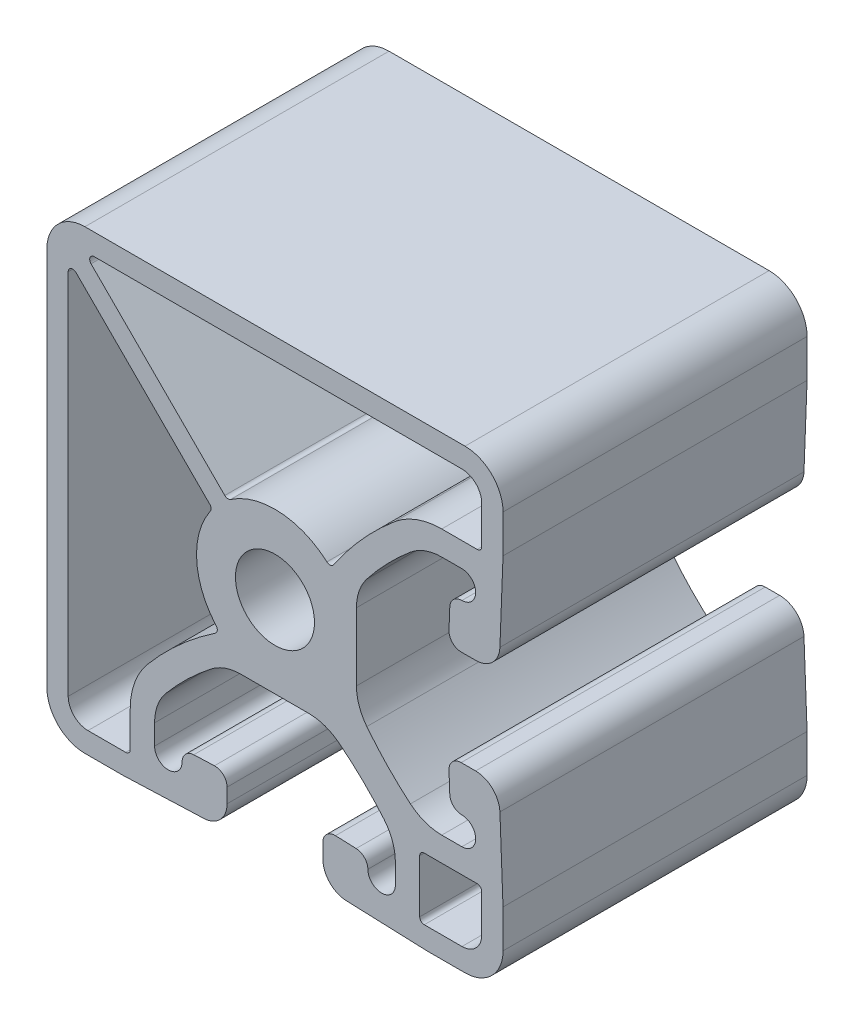
from build123d import *

# Parameters (mm, degrees)
SKETCH1_R      = 3.302
EXTRUDE1_DEPTH = 25.4


with BuildPart() as part:
    # Sketch1 → Extrude1 (new body)
    with BuildSketch(Plane.XY):
        with BuildLine():
            Line((15.875, 19.05), (-15.875, 19.05))
            ThreePointArc((-15.875, 19.05), (-18.12006403, 18.12006403), (-19.05, 15.875))
            Line((-19.05, 15.875), (-19.05, -15.875))
            ThreePointArc((-19.05, -15.875), (-18.12006403, -18.12006403), (-15.875, -19.05))
            Line((-15.875, -19.05), (-12.7, -19.05))
            Line((-12.7, -19.05), (-5.954495972, -18.790863874))
            ThreePointArc((-5.954495972, -18.790863874), (-4.568340141, -18.169354143), (-4.0005, -16.760361628))
            Line((-4.0005, -16.760361628), (-4.0005, -15.552069001))
            ThreePointArc((-4.0005, -15.552069001), (-4.312003742, -14.819989072), (-5.055502014, -14.536817878))
            Line((-5.055502014, -14.536817878), (-6.782702014, -14.603170209))
            ThreePointArc((-6.782702014, -14.603170209), (-7.475165883, -14.913287543), (-7.759698458, -15.616651022))
            ThreePointArc((-7.759698458, -15.616651022), (-8.91004969, -16.763999564), (-10.0584, -15.614648356))
            Line((-10.0584, -15.614648356), (-10.0584, -13.931647412))
            ThreePointArc((-10.0584, -13.931647412), (-9.812696364, -12.53999053), (-9.105295238, -11.316608824))
            ThreePointArc((-9.105295238, -11.316608824), (-7.314841404, -9.397406099), (-5.335891418, -7.673219048))
            ThreePointArc((-5.335891418, -7.673219048), (-4.154656747, -7.029801128), (-2.828100791, -6.8072))
            Line((-2.828100791, -6.8072), (0, -6.8072))
            Line((0, -6.8072), (2.828100791, -6.8072))
            ThreePointArc((2.828100791, -6.8072), (4.154656747, -7.029801128), (5.335891418, -7.673219048))
            ThreePointArc((5.335891418, -7.673219048), (7.314841404, -9.397406099), (9.105295238, -11.316608824))
            ThreePointArc((9.105295238, -11.316608824), (9.812696364, -12.53999053), (10.0584, -13.931647412))
            Line((10.0584, -13.931647412), (10.0584, -15.614648356))
            ThreePointArc((10.0584, -15.614648356), (8.91004969, -16.763999564), (7.759698458, -15.616651022))
            ThreePointArc((7.759698458, -15.616651022), (7.475165883, -14.913287543), (6.782702014, -14.603170209))
            Line((6.782702014, -14.603170209), (5.055502014, -14.536817878))
            ThreePointArc((5.055502014, -14.536817878), (4.312003742, -14.819989072), (4.0005, -15.552069001))
            Line((4.0005, -15.552069001), (4.0005, -16.760361628))
            ThreePointArc((4.0005, -16.760361628), (4.568340141, -18.169354143), (5.954495972, -18.790863874))
            Line((5.954495972, -18.790863874), (12.7, -19.05))
            Line((12.7, -19.05), (15.875, -19.05))
            ThreePointArc((15.875, -19.05), (18.12006403, -18.12006403), (19.05, -15.875))
            Line((19.05, -15.875), (19.05, -12.7))
            Line((19.05, -12.7), (18.790863874, -5.954495972))
            ThreePointArc((18.790863874, -5.954495972), (18.169354143, -4.568340141), (16.760361628, -4.0005))
            Line((16.760361628, -4.0005), (15.552069001, -4.0005))
            ThreePointArc((15.552069001, -4.0005), (14.819989072, -4.312003742), (14.536817878, -5.055502014))
            Line((14.536817878, -5.055502014), (14.603170209, -6.782702014))
            ThreePointArc((14.603170209, -6.782702014), (14.913287543, -7.475165883), (15.616651022, -7.759698458))
            ThreePointArc((15.616651022, -7.759698458), (16.763999564, -8.91004969), (15.614648356, -10.0584))
            Line((15.614648356, -10.0584), (13.931647412, -10.0584))
            ThreePointArc((13.931647412, -10.0584), (12.53999053, -9.812696364), (11.316608824, -9.105295238))
            ThreePointArc((11.316608824, -9.105295238), (9.397406099, -7.314841404), (7.673219048, -5.335891418))
            ThreePointArc((7.673219048, -5.335891418), (7.029801128, -4.154656747), (6.8072, -2.828100791))
            Line((6.8072, -2.828100791), (6.8072, 0))
            Line((6.8072, 0), (6.8072, 2.828100791))
            ThreePointArc((6.8072, 2.828100791), (7.029801128, 4.154656747), (7.673219048, 5.335891418))
            ThreePointArc((7.673219048, 5.335891418), (9.397406099, 7.314841404), (11.316608824, 9.105295238))
            ThreePointArc((11.316608824, 9.105295238), (12.53999053, 9.812696364), (13.931647412, 10.0584))
            Line((13.931647412, 10.0584), (15.614648356, 10.0584))
            ThreePointArc((15.614648356, 10.0584), (16.763999564, 8.91004969), (15.616651022, 7.759698458))
            ThreePointArc((15.616651022, 7.759698458), (14.913287543, 7.475165883), (14.603170209, 6.782702014))
            Line((14.603170209, 6.782702014), (14.536817878, 5.055502014))
            ThreePointArc((14.536817878, 5.055502014), (14.819989072, 4.312003742), (15.552069001, 4.0005))
            Line((15.552069001, 4.0005), (16.760361628, 4.0005))
            ThreePointArc((16.760361628, 4.0005), (18.169354143, 4.568340141), (18.790863874, 5.954495972))
            Line((18.790863874, 5.954495972), (19.05, 12.7))
            Line((19.05, 12.7), (19.05, 15.875))
            ThreePointArc((19.05, 15.875), (18.12006403, 18.12006403), (15.875, 19.05))
        make_face()
        Circle(SKETCH1_R, mode=Mode.SUBTRACT)
        with BuildLine():
            Line((-4.191663684, 5.448899541), (-15.364356459, 16.621592316))
            ThreePointArc((-15.364356459, 16.621592316), (-15.446946878, 17.036802388), (-15.094948776, 17.272))
            Line((-15.094948776, 17.272), (15.621, 17.272))
            ThreePointArc((15.621, 17.272), (16.788433296, 16.788433296), (17.272, 15.621))
            Line((17.272, 15.621), (17.272, 12.4714))
            ThreePointArc((17.272, 12.4714), (17.160407684, 12.201992316), (16.891, 12.0904))
            Line((16.891, 12.0904), (13.931647412, 12.0904))
            ThreePointArc((13.931647412, 12.0904), (11.84416209, 11.721844546), (10.00908953, 10.660742857))
            ThreePointArc((10.00908953, 10.660742857), (7.259428949, 8.000870719), (4.906547928, 4.984332303))
            ThreePointArc((4.906547928, 4.984332303), (4.638901343, 4.819224111), (4.338293085, 4.91158257))
            ThreePointArc((4.338293085, 4.91158257), (0.40044901, 6.540953358), (-3.706747429, 5.40411452))
            ThreePointArc((-3.706747429, 5.40411452), (-3.957294594, 5.338921804), (-4.191663684, 5.448899541))
        make_face(mode=Mode.SUBTRACT)
        with BuildLine():
            Line((-5.448899541, 4.191663684), (-16.621592316, 15.364356459))
            ThreePointArc((-16.621592316, 15.364356459), (-17.036802388, 15.446946878), (-17.272, 15.094948776))
            Line((-17.272, 15.094948776), (-17.272, -15.621))
            ThreePointArc((-17.272, -15.621), (-16.788433296, -16.788433296), (-15.621, -17.272))
            Line((-15.621, -17.272), (-12.4714, -17.272))
            ThreePointArc((-12.4714, -17.272), (-12.201992316, -17.160407684), (-12.0904, -16.891))
            Line((-12.0904, -16.891), (-12.0904, -13.931647412))
            ThreePointArc((-12.0904, -13.931647412), (-11.721844546, -11.84416209), (-10.660742857, -10.00908953))
            ThreePointArc((-10.660742857, -10.00908953), (-8.000870719, -7.259428949), (-4.984332303, -4.906547928))
            ThreePointArc((-4.984332303, -4.906547928), (-4.819224111, -4.638901343), (-4.91158257, -4.338293085))
            ThreePointArc((-4.91158257, -4.338293085), (-6.540953358, -0.40044901), (-5.40411452, 3.706747429))
            ThreePointArc((-5.40411452, 3.706747429), (-5.338921804, 3.957294594), (-5.448899541, 4.191663684))
        make_face(mode=Mode.SUBTRACT)
        with BuildLine():
            Line((12.4714, -12.0904), (16.891, -12.0904))
            ThreePointArc((16.891, -12.0904), (17.160407684, -12.201992316), (17.272, -12.4714))
            Line((17.272, -12.4714), (17.272, -15.621))
            ThreePointArc((17.272, -15.621), (16.788433296, -16.788433296), (15.621, -17.272))
            Line((15.621, -17.272), (12.4714, -17.272))
            ThreePointArc((12.4714, -17.272), (12.201992316, -17.160407684), (12.0904, -16.891))
            Line((12.0904, -16.891), (12.0904, -12.4714))
            ThreePointArc((12.0904, -12.4714), (12.201992316, -12.201992316), (12.4714, -12.0904))
        make_face(mode=Mode.SUBTRACT)
    extrude(amount=EXTRUDE1_DEPTH)


solid = part.part
